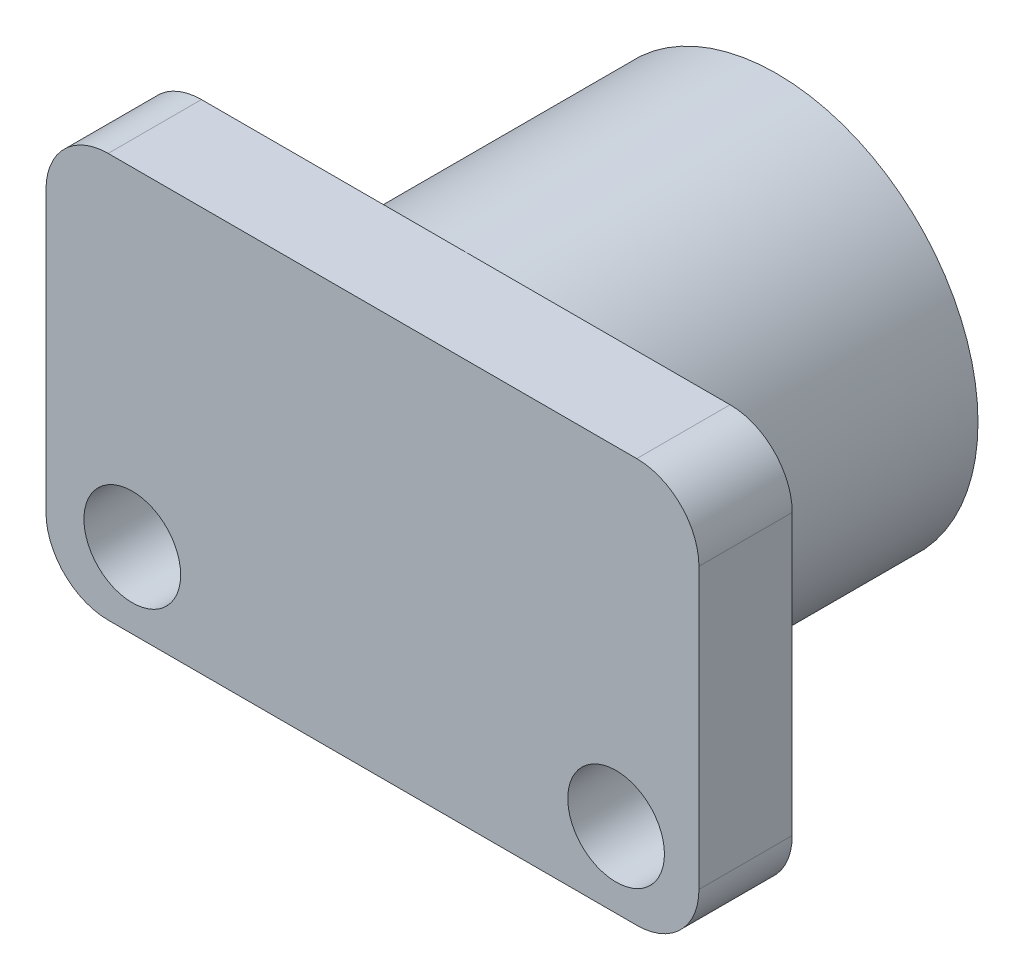
from build123d import *

# Parameters (mm, degrees)
ESQUISSE1_W             = 21
ESQUISSE1_H             = 13
BOSS_EXTRU_1_DEPTH      = 3
CONG_1_R                = 2
ESQUISSE2_R             = 1.555
ENL_V_MAT_EXTRU_1_DEPTH = 4
ESQUISSE3_R             = 6.475
BOSS_EXTRU_2_DEPTH      = 10
ESQUISSE4_R             = 5.065
ENL_V_MAT_EXTRU_2_DEPTH = 10


with BuildPart() as part:
    # Esquisse1 → Boss.-Extru.1 (new body)
    with BuildSketch(Plane.XY):
        Rectangle(ESQUISSE1_W, ESQUISSE1_H)
    extrude(amount=BOSS_EXTRU_1_DEPTH)

    # Congé1
    cong_1_edges = [part.edges().sort_by_distance(p)[0] for p in [
        (-10.5, 6.5, 1.5),
        (10.5, 6.5, 1.5),
        (10.5, -6.5, 1.5),
        (-10.5, -6.5, 1.5),
    ]]
    fillet(cong_1_edges, radius=CONG_1_R)

    # Esquisse2 → Enlèv. mat.-Extru.1 (cut, through all)
    with BuildSketch(Plane.XY.offset(3)):
        with Locations((-7.725, -4.074069474)):
            Circle(ESQUISSE2_R)
        with Locations((7.835, -4.074069474)):
            Circle(ESQUISSE2_R)
    extrude(amount=-ENL_V_MAT_EXTRU_1_DEPTH, mode=Mode.SUBTRACT)

    # Esquisse3 → Boss.-Extru.2 (add)
    with BuildSketch(Plane(origin=(0, 0, 0), x_dir=(-1, 0, 0), z_dir=(0, 0, -1))):
        Circle(ESQUISSE3_R)
    extrude(amount=BOSS_EXTRU_2_DEPTH)

    # Esquisse4 → Enlèv. mat.-Extru.2 (cut)
    with BuildSketch(Plane(origin=(0, 0, -10), x_dir=(-1, 0, 0), z_dir=(0, 0, -1))):
        Circle(ESQUISSE4_R)
    extrude(amount=-ENL_V_MAT_EXTRU_2_DEPTH, mode=Mode.SUBTRACT)


solid = part.part
